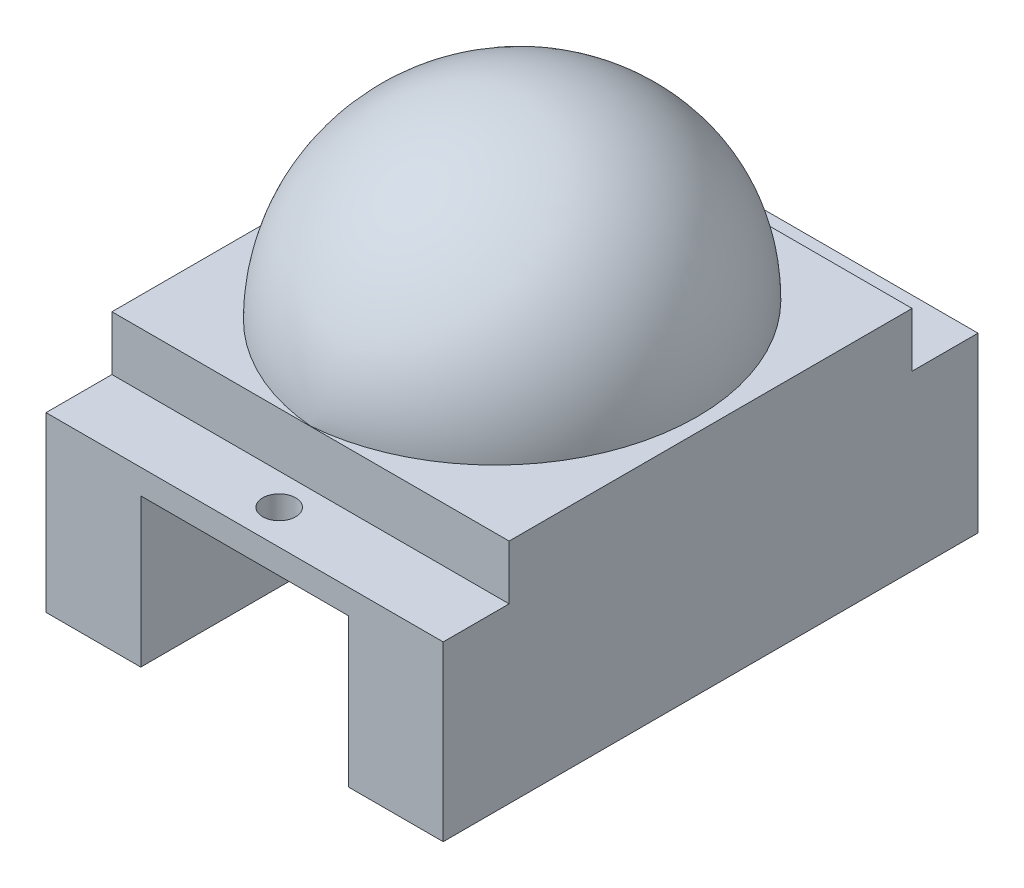
from build123d import *

# Parameters (mm, degrees)
SKETCH1_W                = 24.1
SKETCH1_H                = 32.45
SKETCH1_R                = 1
BOSS_EXTRUDE1_DEPTH      = 1.5
SKETCH3_W                = 24.1
SKETCH3_H                = 24.45
BOSS_EXTRUDE2_DEPTH      = 3.3
SKETCH4_W                = 5.75
SKETCH4_H                = 32.45
BOSS_EXTRUDE3_DEPTH      = 9
REVOLVE1_ANGLE           = 90
REVOLVE1_OTHER_WAY_ANGLE = 90


with BuildPart() as part:
    # Sketch1 → Boss-Extrude1 (new body)
    with BuildSketch(Plane(origin=(0, 0, 0), x_dir=(1, 0, 0), z_dir=(0, 1, 0))):
        Rectangle(SKETCH1_W, SKETCH1_H)
        with Locations((0, 14.125)):
            Circle(SKETCH1_R, mode=Mode.SUBTRACT)
        with Locations((0, -14.125)):
            Circle(SKETCH1_R, mode=Mode.SUBTRACT)
    extrude(amount=BOSS_EXTRUDE1_DEPTH)

    # Sketch3 → Boss-Extrude2 (add)
    with BuildSketch(Plane(origin=(0, 1.5, 0), x_dir=(1, 0, 0), z_dir=(0, 1, 0))):
        Rectangle(SKETCH3_W, SKETCH3_H)
    extrude(amount=BOSS_EXTRUDE2_DEPTH)

    # Sketch4 → Boss-Extrude3 (add)
    with BuildSketch(Plane.XZ):
        with Locations((-9.175, 0)):
            Rectangle(SKETCH4_W, SKETCH4_H)
        Polygon((12.05, 16.225), (6.3, 16.225), (6.3, 15.815544674), (6.3, -16.225), (12.05, -16.225), (12.05, 15.815544674), align=None)
    extrude(amount=BOSS_EXTRUDE3_DEPTH)

    # Sketch5 → Revolve1 (revolve)
    with BuildSketch(Plane(origin=(0, 0, 0), x_dir=(0, 0, -1), z_dir=(1, 0, 0))):
        with BuildLine():
            Line((-12.208392976, 4.8), (12.225, 4.8))
            ThreePointArc((12.225, 4.8), (0.008303512, 16.025033292), (-12.208392976, 4.8))
        make_face()
    revolve(axis=Axis((0, 4.8, 12.208392976), (0, 0, -1)), revolution_arc=REVOLVE1_ANGLE)

    # Sketch5 → Revolve1 other way (revolve)
    with BuildSketch(Plane(origin=(0, 0, 0), x_dir=(0, 0, -1), z_dir=(1, 0, 0))):
        with BuildLine():
            Line((-12.208392976, 4.8), (12.225, 4.8))
            ThreePointArc((12.225, 4.8), (0.008303512, 16.025033292), (-12.208392976, 4.8))
        make_face()
    revolve(axis=Axis((0, 4.8, 12.208392976), (0, 0, 1)), revolution_arc=REVOLVE1_OTHER_WAY_ANGLE)


solid = part.part
